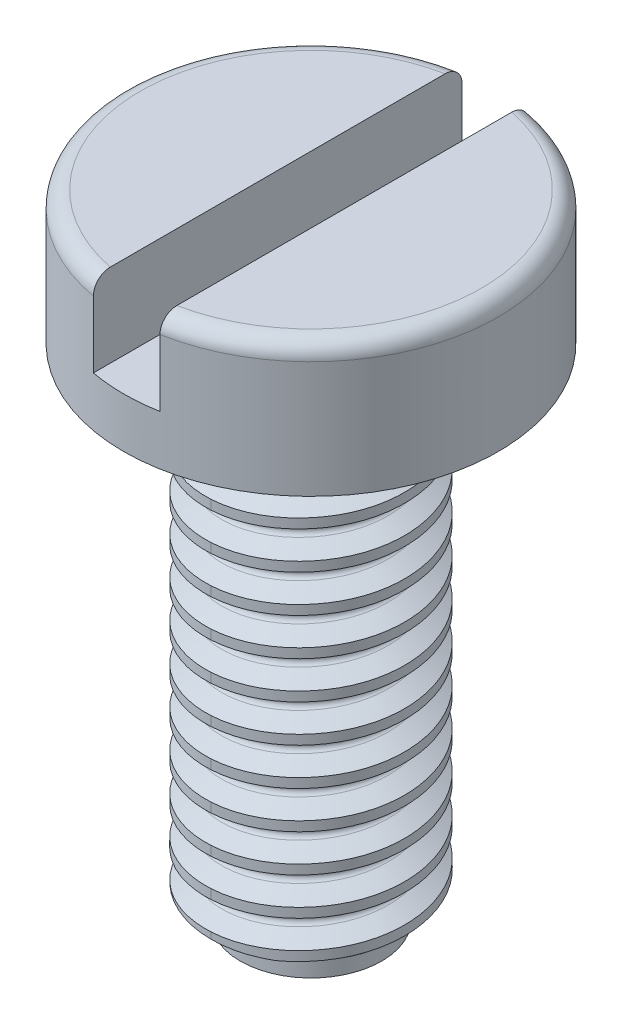
from build123d import *

# Parameters (mm, degrees)
SKETCH2_W               = 0.8
SKETCH2_H               = 1
CUT_EXTRUDE1_DEPTH      = 3.25
CUT_EXTRUDE1_DEPTH_BACK = 3.2500001
CUT_SWEEP1_PITCH        = 0.45
CUT_SWEEP1_HEIGHT       = 5.5125
CUT_SWEEP1_RADIUS       = 1.25
CUT_EXTRUDE2_DEPTH      = 2


with BuildPart() as part:
    # Sketch1 → Revolve1 (revolve)
    with BuildSketch(Plane.XY, mode=Mode.PRIVATE) as revolve1_sk:
        with BuildLine():
            Line((0, 0), (0.85, 0))
            Line((0.85, 0), (0.85, 0.2))
            Line((0.85, 0.2), (1.2, 0.402072594))
            Line((1.2, 0.402072594), (1.2, 6))
            Line((1.2, 6), (2.25, 6))
            Line((2.25, 6), (2.25, 7.4))
            ThreePointArc((2.25, 7.4), (2.191421356, 7.541421356), (2.05, 7.6))
            Line((2.05, 7.6), (0, 7.6))
            Line((0, 7.6), (0, 0))
        make_face()
    revolve(revolve1_sk.sketch.rotate(Axis((0, 55, 0), (0, -1, 0)), 90), axis=Axis((0, 55, 0), (0, -1, 0)))  # turned: the seam where the file's is

    # Sketch2 → Cut-Extrude1 (cut, two sides)
    with BuildSketch(Plane.XY) as cut_extrude1_sk:
        with Locations((0, 7.1)):
            Rectangle(SKETCH2_W, SKETCH2_H)
    extrude(amount=CUT_EXTRUDE1_DEPTH, mode=Mode.SUBTRACT)
    extrude(cut_extrude1_sk.sketch, amount=-CUT_EXTRUDE1_DEPTH_BACK, mode=Mode.SUBTRACT)

    # Cut-Sweep1: sweep along a helix
    with BuildLine() as cut_sweep1_path:
        Helix(CUT_SWEEP1_PITCH, CUT_SWEEP1_HEIGHT, CUT_SWEEP1_RADIUS, center=(0, 0, 0), direction=(0, 1, 0))
    # Sketch4 → Cut-Sweep1 (sweep, cut)
    with BuildSketch(Plane(origin=(0, 0, 0), x_dir=(0, 0, -1), z_dir=(1, 0, 0))):
        with BuildLine():
            Line((-1.25, 0), (-1.006430355, 0.140625))
            ThreePointArc((-1.006430355, 0.140625), (-0.973954403, 0.196875), (-1.006430355, 0.253125))
            Line((-1.006430355, 0.253125), (-1.25, 0.39375))
            Line((-1.25, 0.39375), (-1.25, 0))
        make_face()
    sweep(path=cut_sweep1_path.line, is_frenet=True, mode=Mode.SUBTRACT)

    # Sketch5 → Cut-Extrude2 (cut)
    with BuildSketch(Plane.XY):
        with BuildLine():
            Line((1.2, 5.877382487), (1.006430355, 5.765625))
            add(Edge.make_bspline(
                [(1.006430355, 5.765625), (0.973504506, 5.745788291), (0.973954403, 5.709375), (0.974411047, 5.672415549), (1.006430355, 5.653125)],
                knots=[0, 0, 0, 0.5, 0.5, 1, 1, 1], degree=2))
            Line((1.006430355, 5.653125), (1.2, 5.541367513))
            Line((1.2, 5.541367513), (1.2, 5.877382487))
        make_face()
    extrude(amount=-CUT_EXTRUDE2_DEPTH, mode=Mode.SUBTRACT)


solid = part.part
